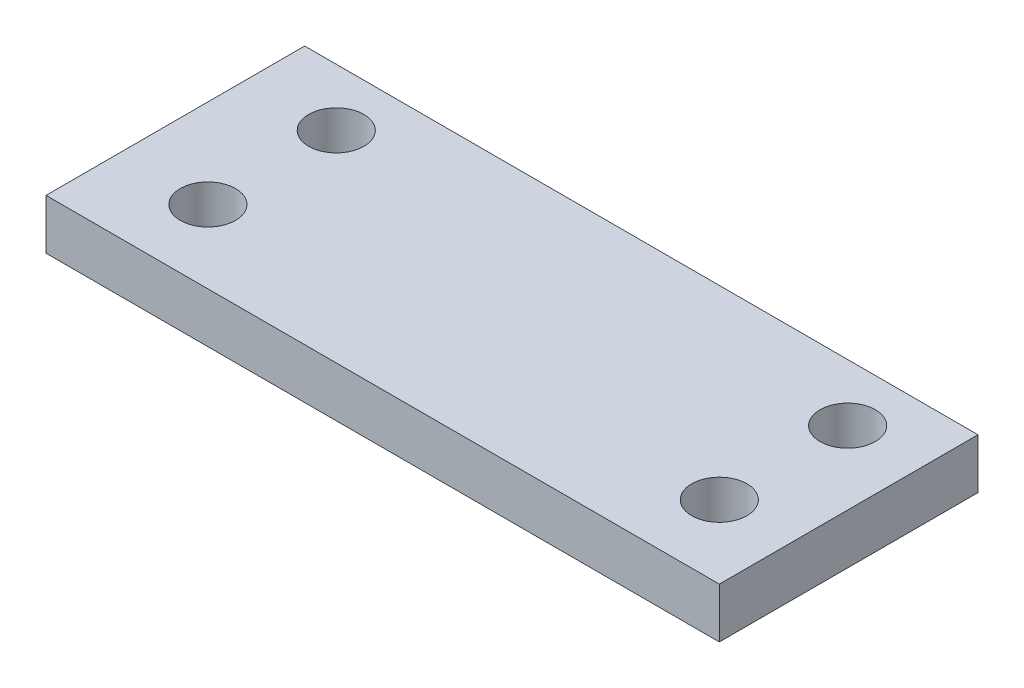
from build123d import *

# Parameters (mm, degrees)
SKETCH2_W           = 134.338034086
SKETCH2_H           = 51.607866468
SKETCH2_R           = 5.515344508
BOSS_EXTRUDE1_DEPTH = 10


with BuildPart() as part:
    # Sketch2 → Boss-Extrude1 (new body)
    with BuildSketch(Plane(origin=(0, 0, 0), x_dir=(1, 0, 0), z_dir=(0, 1, 0))):
        with Locations((-6.500227456, 5.909297687)):
            Rectangle(SKETCH2_W, SKETCH2_H)
        with Locations((-55.941351438, 20.288588726)):
            Circle(SKETCH2_R, mode=Mode.SUBTRACT)
        with Locations((-55.941351438, -5.318367918)):
            Circle(SKETCH2_R, mode=Mode.SUBTRACT)
        with Locations((46.092521959, -5.318367918)):
            Circle(SKETCH2_R, mode=Mode.SUBTRACT)
        with Locations((46.092521959, 20.288588726)):
            Circle(SKETCH2_R, mode=Mode.SUBTRACT)
    extrude(amount=BOSS_EXTRUDE1_DEPTH)


solid = part.part
